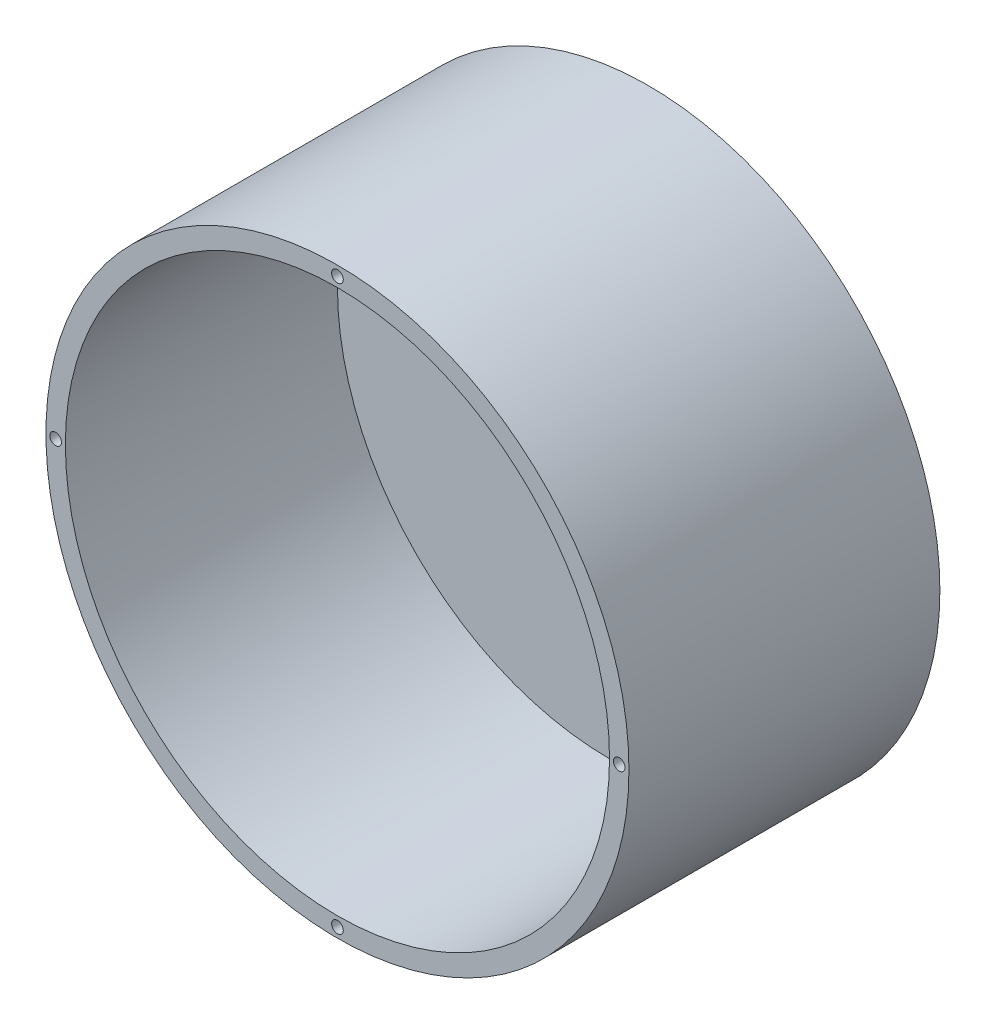
from build123d import *

# Parameters (mm, degrees)
SKETCH1_R           = 37.5
SKETCH1_R_2         = 35
BOSS_EXTRUDE1_DEPTH = 40
SKETCH2_R           = 35
BOSS_EXTRUDE2_DEPTH = 5
SKETCH3_R           = 0.75
CUT_EXTRUDE1_DEPTH  = 5


with BuildPart() as part:
    # Sketch1 → Boss-Extrude1 (new body)
    with BuildSketch(Plane.XY):
        Circle(SKETCH1_R)
        Circle(SKETCH1_R_2, mode=Mode.SUBTRACT)
    extrude(amount=BOSS_EXTRUDE1_DEPTH)

    # Sketch2 → Boss-Extrude2 (add)
    with BuildSketch(Plane(origin=(0, 0, 0), x_dir=(-1, 0, 0), z_dir=(0, 0, -1))):
        Circle(SKETCH2_R)
    extrude(amount=-BOSS_EXTRUDE2_DEPTH)

    # Sketch3 → Cut-Extrude1 (cut)
    with BuildSketch(Plane.XY.offset(40)):
        with Locations((0, 36.25)):
            Circle(SKETCH3_R)
        with Locations((36.25, 0)):
            Circle(SKETCH3_R)
        with Locations((0, -36.25)):
            Circle(SKETCH3_R)
        with Locations((-36.25, 0)):
            Circle(SKETCH3_R)
    extrude(amount=-CUT_EXTRUDE1_DEPTH, mode=Mode.SUBTRACT)


solid = part.part
